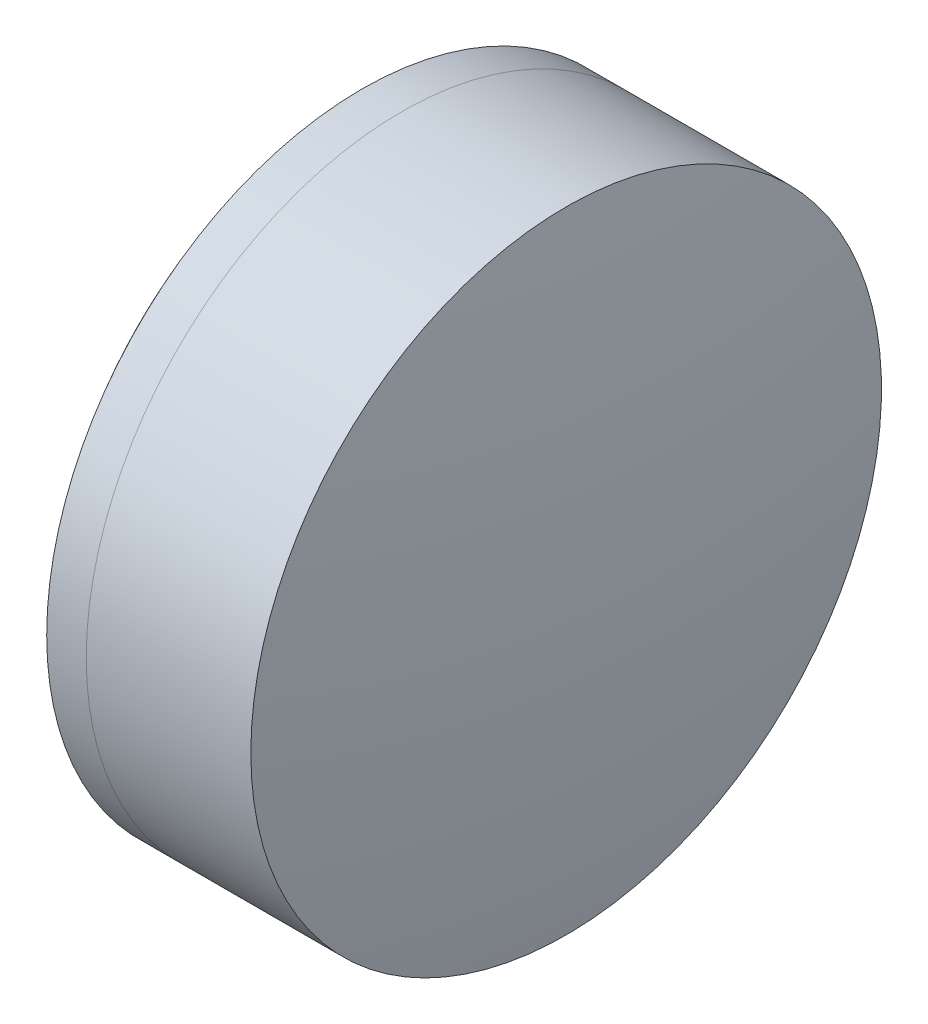
from build123d import *


with BuildPart() as part:
    # 草图1 one side → 旋转1 (revolve)
    with BuildSketch(Plane(origin=(0, 0, 0), x_dir=(1, 0, 0), z_dir=(0, 1, 0)), mode=Mode.PRIVATE) as revolve_1_sk:
        with BuildLine():
            ThreePointArc((272.911584736, 12.7), (269.750375298, 6.696539989), (268.658986555, 0))
            Line((268.658986555, 0), (280.658986555, 0))
            ThreePointArc((280.658986555, 0), (279.0391777, 7.056432088), (274.504075083, 12.7))
            Line((274.504075083, 12.7), (272.911584736, 12.7))
        make_face()
    revolve(revolve_1_sk.sketch.rotate(Axis((124.523309526, 0, 0), (1, 0, 0)), 180), axis=Axis((124.523309526, 0, 0), (1, 0, 0)))  # turned: the seam where the file's is


with BuildPart() as body_2:
    # 草图2 one side → 旋转3 (revolve)
    with BuildSketch(Plane(origin=(0, 0, 0), x_dir=(1, 0, 0), z_dir=(0, 1, 0)), mode=Mode.PRIVATE) as revolve_3_sk:
        with BuildLine():
            Line((281.13253484, 12.7), (274.504075083, 12.7))
            ThreePointArc((274.504075083, 12.7), (279.0391777, 7.056432088), (280.658986555, 0))
            Line((280.658986555, 0), (282.158986555, 0))
            ThreePointArc((282.158986555, 0), (281.901955918, 6.370706459), (281.13253484, 12.7))
        make_face()
    revolve(revolve_3_sk.sketch.rotate(Axis((-0.551919993, 0, 0), (1, 0, 0)), 180), axis=Axis((-0.551919993, 0, 0), (1, 0, 0)))  # turned: the seam where the file's is


solid = Compound([part.part, body_2.part])
